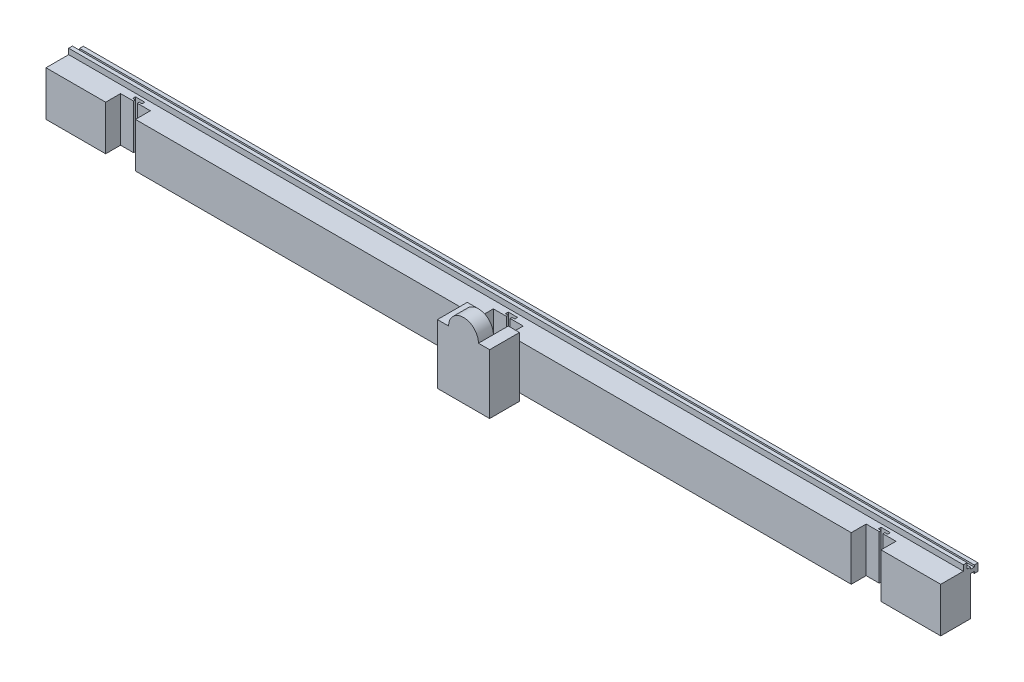
from build123d import *

# Parameters (mm, degrees)
SKETCH2_W                = 6096
SKETCH2_H                = 304.8
BOSS_EXTRUDE1_DEPTH      = 203.2
CUT_EXTRUDE1_DEPTH       = 305.8
LPATTERN1_COUNT          = 2
LPATTERN1_PITCH          = 2540
LPATTERN1_COL_COUNT      = 2
LPATTERN1_COL_PITCH      = 2540
SKETCH5_W                = 6096
SKETCH5_H                = 25.4
BOSS_EXTRUDE2_DEPTH      = 38.1
SKETCH7_W                = 203.2
SKETCH7_H                = 101.6
CUT_EXTRUDE2_DEPTH       = 305.8
LPATTERN2_COUNT          = 2
LPATTERN2_PITCH          = 2540
LPATTERN2_COL_COUNT      = 2
LPATTERN2_COL_PITCH      = 2540
BOSS_EXTRUDE4_DEPTH      = 6096
BOSS_EXTRUDE5_DEPTH      = 50.8
BOSS_EXTRUDE5_DEPTH_BACK = 355.6
BOSS_EXTRUDE6_DEPTH      = 101.6


with BuildPart() as part:
    # Sketch2 → Boss-Extrude1 (new body)
    with BuildSketch(Plane.XY):
        Rectangle(SKETCH2_W, SKETCH2_H)
    extrude(amount=-BOSS_EXTRUDE1_DEPTH)

    # Sketch4 → Cut-Extrude1 (cut, through all)
    with BuildSketch(Plane(origin=(0, 152.4, 0), x_dir=(1, 0, 0), z_dir=(0, 1, 0))):
        Polygon((-75.851698824, 0), (75.851698824, 0), (75.851698824, 101.6), (12.7, 101.6), (12.7, 114.3), (31.75, 114.3), (31.75, 133.35), (-31.75, 133.35), (-31.75, 114.3), (-12.7, 114.3), (-12.7, 101.6), (-75.851698824, 101.6), align=None)
    cut_extrude1 = extrude(amount=-CUT_EXTRUDE1_DEPTH, mode=Mode.SUBTRACT)

    # LPattern1: Cut-Extrude1 ×2
    with Locations(*[(-i * LPATTERN1_PITCH, 0, 0) for i in range(1, LPATTERN1_COUNT)]):
        add(cut_extrude1, mode=Mode.SUBTRACT)

    # LPattern1 col: Cut-Extrude1 ×2
    with Locations(*[(i * LPATTERN1_COL_PITCH, 0, 0) for i in range(1, LPATTERN1_COL_COUNT)]):
        add(cut_extrude1, mode=Mode.SUBTRACT)

    # Sketch5 → Boss-Extrude2 (add)
    with BuildSketch(Plane(origin=(0, 152.4, 0), x_dir=(1, 0, 0), z_dir=(0, 1, 0))):
        with Locations((0, 167.160624532)):
            Rectangle(SKETCH5_W, SKETCH5_H)
    extrude(amount=BOSS_EXTRUDE2_DEPTH)

    # Sketch7 → Cut-Extrude2 (cut, through all)
    with BuildSketch(Plane(origin=(0, 152.4, 0), x_dir=(1, 0, 0), z_dir=(0, 1, 0))):
        with Locations((0, 50.8)):
            Rectangle(SKETCH7_W, SKETCH7_H)
    cut_extrude2 = extrude(amount=-CUT_EXTRUDE2_DEPTH, mode=Mode.SUBTRACT)

    # LPattern2: Cut-Extrude2 ×2
    with Locations(*[(-i * LPATTERN2_PITCH, 0, 0) for i in range(1, LPATTERN2_COUNT)]):
        add(cut_extrude2, mode=Mode.SUBTRACT)

    # LPattern2 col: Cut-Extrude2 ×2
    with Locations(*[(i * LPATTERN2_COL_PITCH, 0, 0) for i in range(1, LPATTERN2_COL_COUNT)]):
        add(cut_extrude2, mode=Mode.SUBTRACT)

    # Sketch9 → Boss-Extrude4 (add)
    with BuildSketch(Plane.ZY.offset(3048)):
        Polygon((-228.6, 152.4), (-228.6, 139.7), (-203.2, 139.7), (-203.2, 114.3), (-228.6, 114.3), (-228.6, 101.6), (-254, 101.6), (-254, 152.4), align=None)
    extrude(amount=-BOSS_EXTRUDE4_DEPTH)

    # Sketch10 → Boss-Extrude5 (add, two sides)
    with BuildSketch(Plane(origin=(0, 152.4, 0), x_dir=(1, 0, 0), z_dir=(0, 1, 0))) as boss_extrude5_sk:
        Polygon((-177.8, 0), (-101.6, 0), (-101.6, -101.6), (101.6, -101.6), (101.6, 0), (177.8, 0), (177.8, -203.2), (-177.8, -203.2), align=None)
    extrude(amount=BOSS_EXTRUDE5_DEPTH)
    extrude(boss_extrude5_sk.sketch, amount=-BOSS_EXTRUDE5_DEPTH_BACK)

    # Sketch11 → Boss-Extrude6 (add)
    with BuildSketch(Plane.XY.offset(203.2)):
        with BuildLine():
            Line((-101.6, 203.2), (101.6, 203.2))
            ThreePointArc((101.6, 203.2), (0, 304.8), (-101.6, 203.2))
        make_face()
    extrude(amount=-BOSS_EXTRUDE6_DEPTH)


solid = part.part
